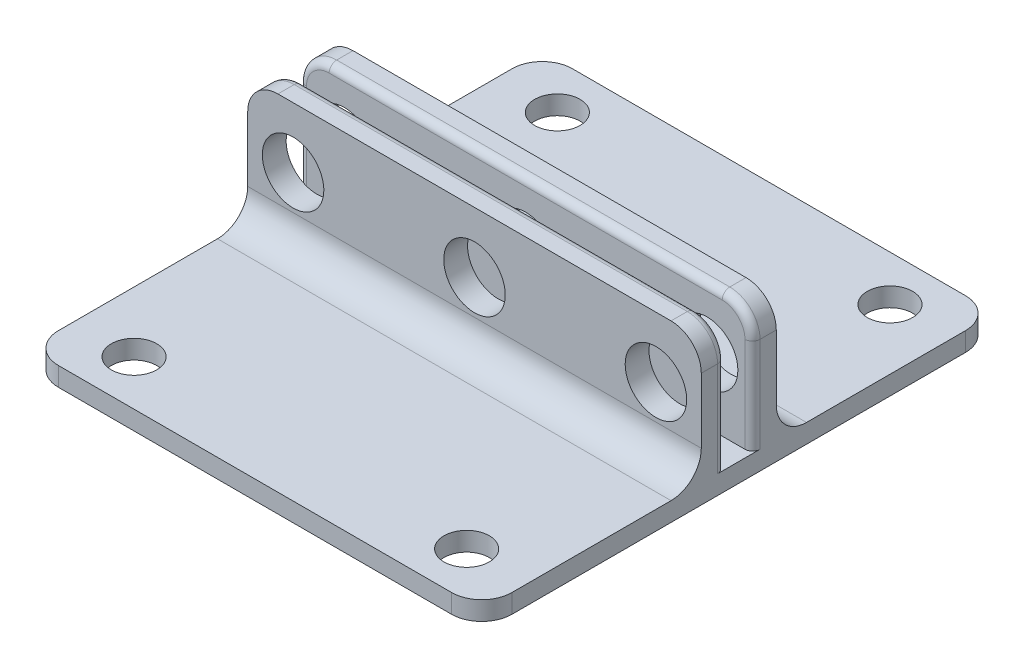
from build123d import *

# Parameters (mm, degrees)
SKETCH1_W               = 38.1
SKETCH1_H               = 43.18
SKETCH1_R               = 1.905
BOSS_EXTRUDE1_DEPTH     = 1.5875
SKETCH2_W               = 2
SKETCH2_H               = 10.5378
BOSS_EXTRUDE2_DEPTH     = 38.1
SKETCH4_R               = 2.58285
CUT_EXTRUDE1_DEPTH      = 19.44
CUT_EXTRUDE1_DEPTH_BACK = 25.74
FILLET1_R               = 2.54
FILLET2_R               = 2.54
FILLET4_R               = 2.54
FILLET5_R               = 0.635


with BuildPart() as part:
    # Sketch1 → Boss-Extrude1 (new body)
    with BuildSketch(Plane(origin=(0, 0, 0), x_dir=(1, 0, 0), z_dir=(0, 1, 0))):
        with Locations((-19.05, 21.59)):
            Rectangle(SKETCH1_W, SKETCH1_H)
        with Locations((-33.02, 39.37)):
            Circle(SKETCH1_R, mode=Mode.SUBTRACT)
        with Locations((-33.02, 3.81)):
            Circle(SKETCH1_R, mode=Mode.SUBTRACT)
        with Locations((-5.08, 3.81)):
            Circle(SKETCH1_R, mode=Mode.SUBTRACT)
        with Locations((-5.08, 39.37)):
            Circle(SKETCH1_R, mode=Mode.SUBTRACT)
    extrude(amount=BOSS_EXTRUDE1_DEPTH)

    # Sketch2 → Boss-Extrude2 (add)
    with BuildSketch(Plane.ZY.offset(38.1)):
        with Locations((-23.74, 6.8564)):
            Rectangle(SKETCH2_W, SKETCH2_H)
        with Locations((-19.44, 6.8564)):
            Rectangle(SKETCH2_W, SKETCH2_H)
    extrude(amount=-BOSS_EXTRUDE2_DEPTH)

    # Sketch4 → Cut-Extrude1 (cut, two sides)
    with BuildSketch(Plane.XY.offset(-18.44)) as cut_extrude1_sk:
        with Locations((-34.29, 7.0453)):
            Circle(SKETCH4_R)
        with Locations((-19.05, 7.0453)):
            Circle(SKETCH4_R)
        with Locations((-3.81, 7.0453)):
            Circle(SKETCH4_R)
    extrude(amount=CUT_EXTRUDE1_DEPTH, mode=Mode.SUBTRACT)
    extrude(cut_extrude1_sk.sketch, amount=-CUT_EXTRUDE1_DEPTH_BACK, mode=Mode.SUBTRACT)

    # Fillet1
    fillet1_edges = [part.edges().sort_by_distance(p)[0] for p in [
        (0, 12.1253, -19.44),
        (-38.1, 12.1253, -19.44),
        (0, 12.1253, -23.74),
        (-38.1, 12.1253, -23.74),
    ]]
    fillet(fillet1_edges, radius=FILLET1_R)

    # Fillet2
    fillet2_edges = [part.edges().sort_by_distance(p)[0] for p in [
        (-19.05, 1.5875, -18.44),
        (-19.05, 1.5875, -24.74),
    ]]
    fillet(fillet2_edges, radius=FILLET2_R)

    # Fillet4
    fillet4_edges = [part.edges().sort_by_distance(p)[0] for p in [
        (0, 0.79375, 0),
        (-38.1, 0.79375, 0),
        (-38.1, 0.79375, -43.18),
        (0, 0.79375, -43.18),
    ]]
    fillet(fillet4_edges, radius=FILLET4_R)

    # Fillet5
    fillet5_edges = [part.edges().sort_by_distance(p)[0] for p in [
        (-38.1, 5.5864, -20.44),
        (0, 5.5864, -22.74),
        (-19.05, 12.1253, -22.74),
        (0, 5.5864, -20.44),
        (-38.1, 5.5864, -22.74),
        (-37.356051224, 11.381351224, -22.74),
        (-0.743948776, 11.381351224, -22.74),
        (-19.05, 12.1253, -20.44),
        (-37.356051224, 11.381351224, -20.44),
        (-0.743948776, 11.381351224, -20.44),
    ]]
    fillet(fillet5_edges, radius=FILLET5_R)


solid = part.part
